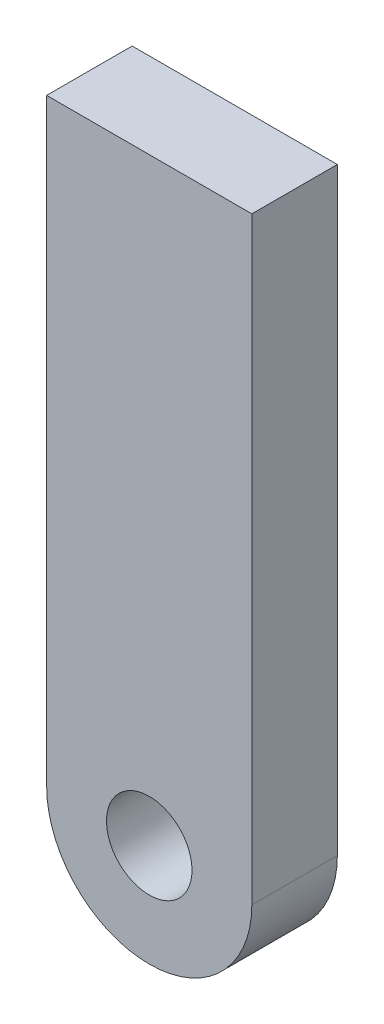
from build123d import *

# Parameters (mm, degrees)
SKETCH1_R           = 3.175
BOSS_EXTRUDE1_DEPTH = 6.35


with BuildPart() as part:
    # Sketch1 → Boss-Extrude1 (new body)
    with BuildSketch(Plane.XY):
        with BuildLine():
            Line((-7.62, 0), (-7.62, 44.45))
            Line((-7.62, 44.45), (7.62, 44.45))
            Line((7.62, 44.45), (7.62, 0))
            ThreePointArc((7.62, 0), (0, -7.62), (-7.62, 0))
        make_face()
        Circle(SKETCH1_R, mode=Mode.SUBTRACT)
    extrude(amount=BOSS_EXTRUDE1_DEPTH)


solid = part.part
